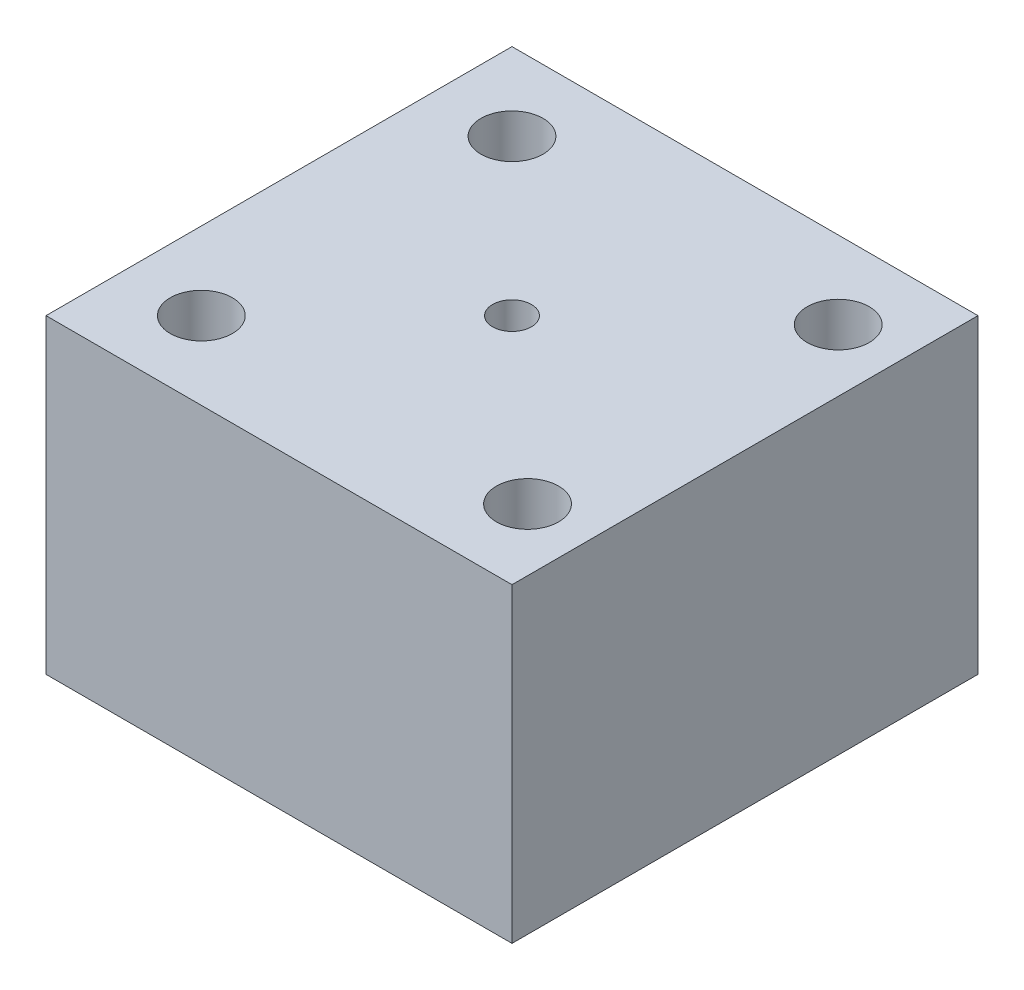
from build123d import *

# Parameters (mm, degrees)
SKETCH1_W           = 30
SKETCH1_H           = 30
BOSS_EXTRUDE1_DEPTH = 20
SKETCH2_R           = 2
SKETCH2_R_2         = 1.25
CUT_EXTRUDE1_DEPTH  = 20


with BuildPart() as part:
    # Sketch1 → Boss-Extrude1 (new body)
    with BuildSketch(Plane(origin=(0, 0, 0), x_dir=(1, 0, 0), z_dir=(0, 1, 0))):
        with Locations((15, 15)):
            Rectangle(SKETCH1_W, SKETCH1_H)
    extrude(amount=BOSS_EXTRUDE1_DEPTH)

    # Sketch2 → Cut-Extrude1 (cut)
    with BuildSketch(Plane(origin=(0, 20, 0), x_dir=(1, 0, 0), z_dir=(0, 1, 0))):
        with Locations((5, 25)):
            Circle(SKETCH2_R)
        with Locations((5, 5)):
            Circle(SKETCH2_R)
        with Locations((26, 5)):
            Circle(SKETCH2_R)
        with Locations((26, 25)):
            Circle(SKETCH2_R)
        with Locations((15, 15)):
            Circle(SKETCH2_R_2)
    extrude(amount=-CUT_EXTRUDE1_DEPTH, mode=Mode.SUBTRACT)


solid = part.part
